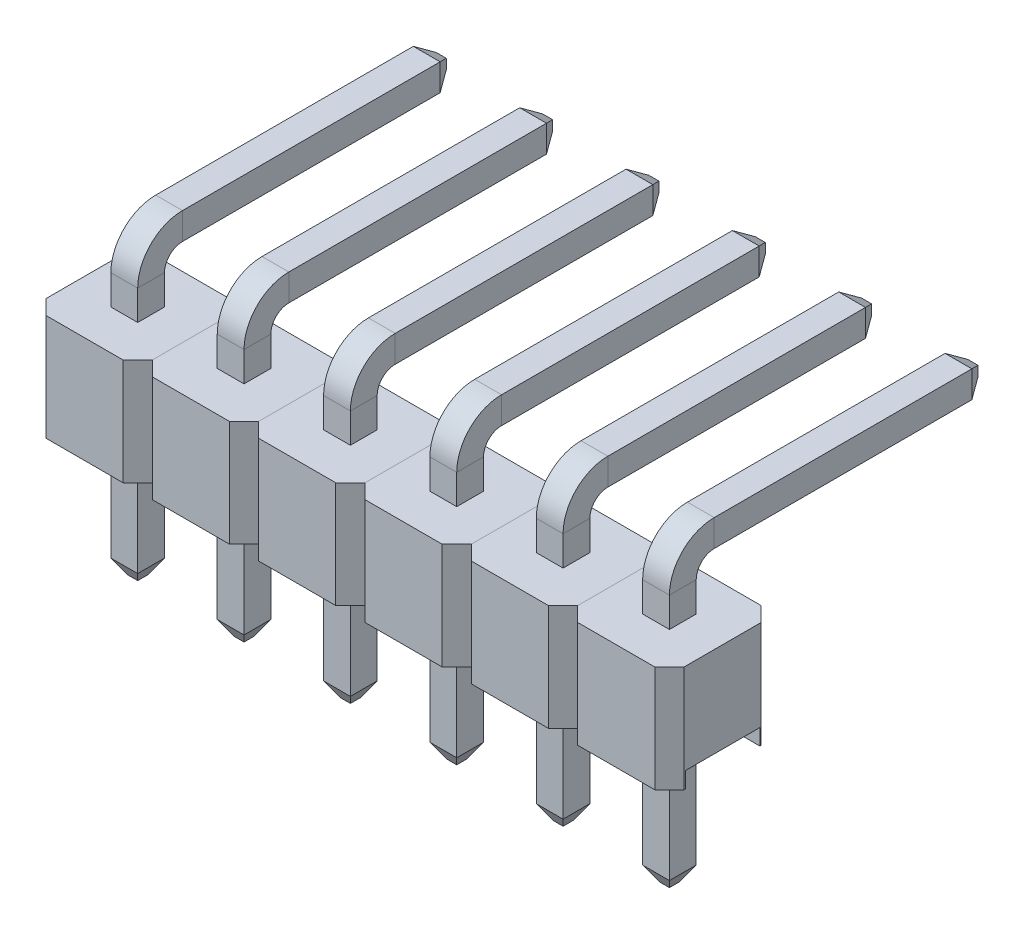
from build123d import *

# Parameters (mm, degrees)
SKETCH1_W             = 2.54
SKETCH1_H             = 2.54
PLASTIC_HOUSING_DEPTH = 2.54
SKETCH3_W             = 1.778
SKETCH3_H             = 0.381
CUT_GROOVE_DEPTH      = 4.81
CHAMF_HOUSING_SIZE    = 0.35
SKETCH2_W             = 0.64
SKETCH2_H             = 0.64
CHAMF_PIN_END_SIZE    = 0.2
CHAMF_PIN_END_SIZE2   = 0.346410162
CHAMF_PIN_START_SIZE  = 0.2
CHAMF_PIN_START_SIZE2 = 0.346410162
PATTERN_SLEEVE_COUNT  = 6
PATTERN_SLEEVE_PITCH  = 2.54
PATTERN_PINS_COUNT    = 6
PATTERN_PINS_PITCH    = 2.54


with BuildPart() as part:
    # Sketch1 → plastic_housing (new body)
    with BuildSketch(Plane(origin=(0, 0, 0), x_dir=(1, 0, 0), z_dir=(0, 1, 0))):
        Rectangle(SKETCH1_W, SKETCH1_H)
    extrude(amount=PLASTIC_HOUSING_DEPTH)

    # Sketch3 → cut groove (cut, through all)
    with BuildSketch(Plane.ZY.offset(1.27)):
        with Locations((0, 0.1905)):
            Rectangle(SKETCH3_W, SKETCH3_H)
    extrude(amount=-CUT_GROOVE_DEPTH, mode=Mode.SUBTRACT)

    # chamf_housing
    chamf_housing_edges = [part.edges().sort_by_distance(p)[0] for p in [
        (1.27, 1.27, 1.27),
        (1.27, 1.27, -1.27),
        (-1.27, 1.27, -1.27),
        (-1.27, 1.27, 1.27),
    ]]
    chamfer(chamf_housing_edges, length=CHAMF_HOUSING_SIZE)


with BuildPart() as body_2:
    # sweep_pin: sweep along a path in Sketch5
    with BuildLine(Plane(origin=(0, 0, 0), x_dir=(0, 0, -1), z_dir=(1, 0, 0))) as sweep_pin_path:
        Line((7.25, 4), (0.75, 4))
        ThreePointArc((0.75, 4), (0.219669914, 3.780330086), (0, 3.25))
        Line((0, 3.25), (0, 0))
        Line((0, 0), (0, -3))
    # Sketch2 → sweep_pin (sweep)
    with BuildSketch(Plane(origin=(0, 2.54, 0), x_dir=(1, 0, 0), z_dir=(0, 1, 0))):
        Rectangle(SKETCH2_W, SKETCH2_H)
    sweep(path=sweep_pin_path.line)

    # chamf_pin_end
    chamf_pin_end_edges = [body_2.edges().sort_by_distance(p)[0] for p in [
        (0, 3.68, -7.25),
        (0.32, 4, -7.25),
        (0, 4.32, -7.25),
        (-0.32, 4, -7.25),
    ]]
    chamf_pin_end_side = [body_2.faces().sort_by_distance(p)[0] for p in [
        (0, 4, -7.25),
    ]]
    chamfer(chamf_pin_end_edges, length=CHAMF_PIN_END_SIZE, length2=CHAMF_PIN_END_SIZE2, reference=chamf_pin_end_side[0])

    # chamf_pin_start
    chamf_pin_start_edges = [body_2.edges().sort_by_distance(p)[0] for p in [
        (0, -3, 0.32),
        (0.32, -3, 0),
        (0, -3, -0.32),
        (-0.32, -3, 0),
    ]]
    chamf_pin_start_side = [body_2.faces().sort_by_distance(p)[0] for p in [
        (0, -3, 0),
    ]]
    chamfer(chamf_pin_start_edges, length=CHAMF_PIN_START_SIZE, length2=CHAMF_PIN_START_SIZE2, reference=chamf_pin_start_side[0])


with BuildPart() as pattern_sleeve_1:
    # pattern SLEEVE: pattern copy
    add(part.part.moved(Location(Vector(-1, 0, 0) * (1 * PATTERN_SLEEVE_PITCH))))


with BuildPart() as pattern_sleeve_2:
    # pattern SLEEVE: pattern copy
    add(part.part.moved(Location(Vector(-1, 0, 0) * (2 * PATTERN_SLEEVE_PITCH))))


with BuildPart() as pattern_sleeve_3:
    # pattern SLEEVE: pattern copy
    add(part.part.moved(Location(Vector(-1, 0, 0) * (3 * PATTERN_SLEEVE_PITCH))))


with BuildPart() as pattern_sleeve_4:
    # pattern SLEEVE: pattern copy
    add(part.part.moved(Location(Vector(-1, 0, 0) * (4 * PATTERN_SLEEVE_PITCH))))


with BuildPart() as pattern_sleeve_5:
    # pattern SLEEVE: pattern copy
    add(part.part.moved(Location(Vector(-1, 0, 0) * (5 * PATTERN_SLEEVE_PITCH))))


with BuildPart() as pattern_pins_1:
    # pattern PINS: pattern copy
    add(body_2.part.moved(Location(Vector(-1, 0, 0) * (1 * PATTERN_PINS_PITCH))))


with BuildPart() as pattern_pins_2:
    # pattern PINS: pattern copy
    add(body_2.part.moved(Location(Vector(-1, 0, 0) * (2 * PATTERN_PINS_PITCH))))


with BuildPart() as pattern_pins_3:
    # pattern PINS: pattern copy
    add(body_2.part.moved(Location(Vector(-1, 0, 0) * (3 * PATTERN_PINS_PITCH))))


with BuildPart() as pattern_pins_4:
    # pattern PINS: pattern copy
    add(body_2.part.moved(Location(Vector(-1, 0, 0) * (4 * PATTERN_PINS_PITCH))))


with BuildPart() as pattern_pins_5:
    # pattern PINS: pattern copy
    add(body_2.part.moved(Location(Vector(-1, 0, 0) * (5 * PATTERN_PINS_PITCH))))


solid = Compound([part.part, body_2.part, pattern_sleeve_1.part, pattern_sleeve_2.part, pattern_sleeve_3.part, pattern_sleeve_4.part, pattern_sleeve_5.part, pattern_pins_1.part, pattern_pins_2.part, pattern_pins_3.part, pattern_pins_4.part, pattern_pins_5.part])
